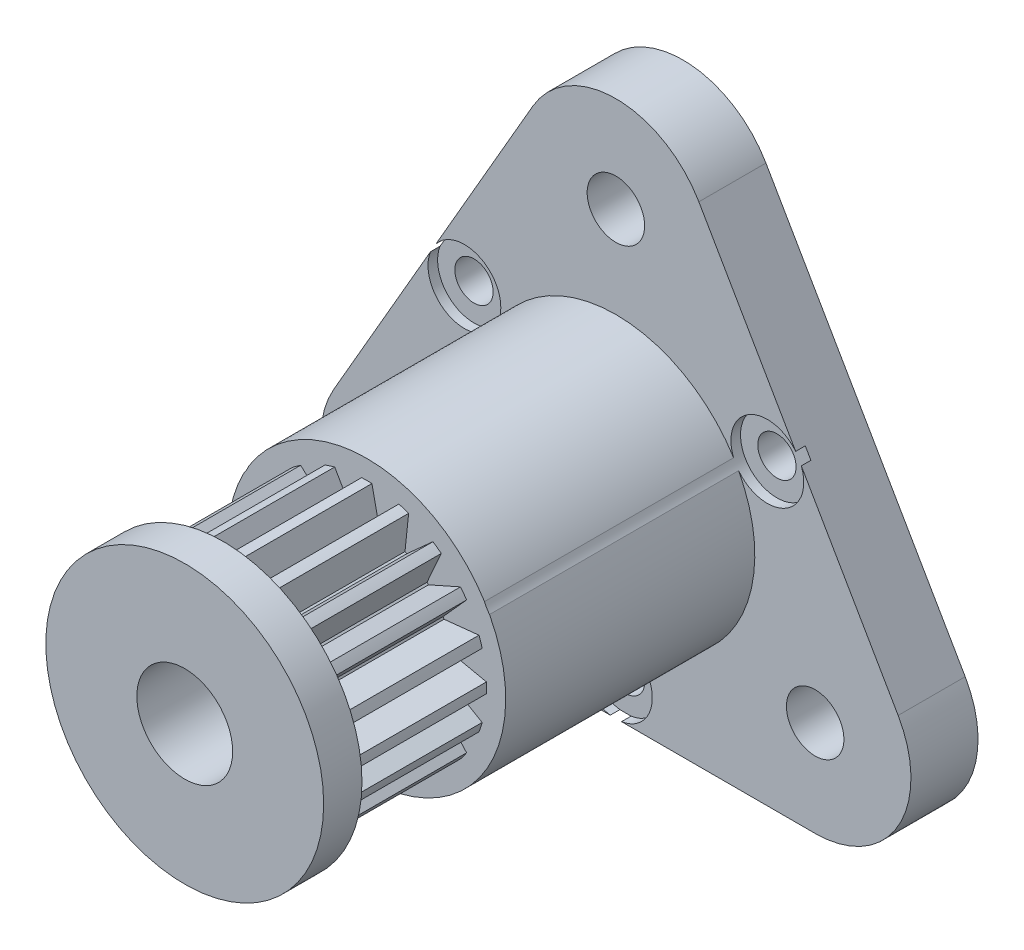
from build123d import *

# Parameters (mm, degrees)
SKETCH1_R               = 1.5
BOSS_EXTRUDE1_DEPTH     = 3.5
SKETCH2_R               = 7.25
BOSS_EXTRUDE2_DEPTH     = 22.5
SKETCH3_R               = 2.5
CUT_EXTRUDE1_DEPTH      = 27
SKETCH6_R               = 9.569614172
CUT_EXTRUDE6_DEPTH      = 7.5
SKETCH7_R               = 17.775779512
SKETCH7_R_2             = 6.25
CUT_EXTRUDE7_DEPTH      = 7.5
SKETCH8_R               = 1
CUT_EXTRUDE8_DEPTH      = 4.5
SKETCH9_R               = 1.9
CUT_EXTRUDE9_DEPTH      = 13
CUT_EXTRUDE9_DEPTH_BACK = 0.5


with BuildPart() as part:
    # Sketch1 → Boss-Extrude1 (new body)
    with BuildSketch(Plane.XY):
        with BuildLine():
            Line((-14.730127019, -3.5044428), (-4.330127019, 14.508885599))
            ThreePointArc((-4.330127019, 14.508885599), (0, 17.008885599), (4.330127019, 14.508885599))
            Line((4.330127019, 14.508885599), (14.730127019, -3.5044428))
            ThreePointArc((14.730127019, -3.5044428), (14.730127019, -8.5044428), (10.4, -11.0044428))
            Line((10.4, -11.0044428), (-10.4, -11.0044428))
            ThreePointArc((-10.4, -11.0044428), (-14.730127019, -8.5044428), (-14.730127019, -3.5044428))
        make_face()
        with Locations((0, 12.008885599)):
            Circle(SKETCH1_R, mode=Mode.SUBTRACT)
        with Locations((-10.4, -6.0044428)):
            Circle(SKETCH1_R, mode=Mode.SUBTRACT)
        with Locations((10.4, -6.0044428)):
            Circle(SKETCH1_R, mode=Mode.SUBTRACT)
    extrude(amount=BOSS_EXTRUDE1_DEPTH)

    # Sketch2 → Boss-Extrude2 (add)
    with BuildSketch(Plane.XY.offset(3.5)):
        Circle(SKETCH2_R)
    extrude(amount=BOSS_EXTRUDE2_DEPTH)

    # Sketch3 → Cut-Extrude1 (cut, through all)
    with BuildSketch(Plane.XY.offset(26)):
        Circle(SKETCH3_R)
    extrude(amount=-CUT_EXTRUDE1_DEPTH, mode=Mode.SUBTRACT)

    # Sketch6 → Cut-Extrude6 (cut)
    with BuildSketch(Plane.XY.offset(24)):
        Circle(SKETCH6_R)
        Polygon((7.5, 0), (4.452808103, 0.65), (4.435733208, 0.757806641), (7.132923872, 2.317627458), (4.034011116, 1.994180112), (3.984457842, 2.091433888), (6.067627458, 4.408389392), (3.220337014, 3.14315598), (3.14315598, 3.220337014), (4.408389392, 6.067627458), (2.091433888, 3.984457842), (1.994180112, 4.034011116), (2.317627458, 7.132923872), (0.757806641, 4.435733208), (0.65, 4.452808103), (0, 7.5), (-0.65, 4.452808103), (-0.757806641, 4.435733208), (-2.317627458, 7.132923872), (-1.994180112, 4.034011116), (-2.091433888, 3.984457842), (-4.408389392, 6.067627458), (-3.14315598, 3.220337014), (-3.220337014, 3.14315598), (-6.067627458, 4.408389392), (-3.984457842, 2.091433888), (-4.034011116, 1.994180112), (-7.132923872, 2.317627458), (-4.435733208, 0.757806641), (-4.452808103, 0.65), (-7.5, 0), (-4.452808103, -0.65), (-4.435733208, -0.757806641), (-7.132923872, -2.317627458), (-4.034011116, -1.994180112), (-3.984457842, -2.091433888), (-6.067627458, -4.408389392), (-3.220337014, -3.14315598), (-3.14315598, -3.220337014), (-4.408389392, -6.067627458), (-2.091433888, -3.984457842), (-1.994180112, -4.034011116), (-2.317627458, -7.132923872), (-0.757806641, -4.435733208), (-0.65, -4.452808103), (0, -7.5), (0.65, -4.452808103), (0.757806641, -4.435733208), (2.317627458, -7.132923872), (1.994180112, -4.034011116), (2.091433888, -3.984457842), (4.408389392, -6.067627458), (3.14315598, -3.220337014), (3.220337014, -3.14315598), (6.067627458, -4.408389392), (3.984457842, -2.091433888), (4.034011116, -1.994180112), (7.132923872, -2.317627458), (4.435733208, -0.757806641), (4.452808103, -0.65), align=None, mode=Mode.SUBTRACT)
    extrude(amount=-CUT_EXTRUDE6_DEPTH, mode=Mode.SUBTRACT)

    # Sketch7 → Cut-Extrude7 (cut)
    with BuildSketch(Plane.XY.offset(24)):
        Circle(SKETCH7_R)
        Circle(SKETCH7_R_2, mode=Mode.SUBTRACT)
    extrude(amount=-CUT_EXTRUDE7_DEPTH, mode=Mode.SUBTRACT)

    # Sketch8 → Cut-Extrude8 (cut, through all)
    with BuildSketch(Plane.XY.offset(3.5)):
        with Locations((7.904405598, 4.5636107)):
            Circle(SKETCH8_R)
        with Locations((0, -9.1272214)):
            Circle(SKETCH8_R)
        with Locations((-7.904405598, 4.5636107)):
            Circle(SKETCH8_R)
    extrude(amount=-CUT_EXTRUDE8_DEPTH, mode=Mode.SUBTRACT)

    # Sketch9 → Cut-Extrude9 (cut, two sides)
    with BuildSketch(Plane.XY.offset(3.5)) as cut_extrude9_sk:
        with Locations((7.904405598, 4.5636107)):
            Circle(SKETCH9_R)
        with Locations((0, -9.1272214)):
            Circle(SKETCH9_R)
        with Locations((-7.904405598, 4.5636107)):
            Circle(SKETCH9_R)
    extrude(amount=CUT_EXTRUDE9_DEPTH, mode=Mode.SUBTRACT)
    extrude(cut_extrude9_sk.sketch, amount=-CUT_EXTRUDE9_DEPTH_BACK, mode=Mode.SUBTRACT)


solid = part.part
